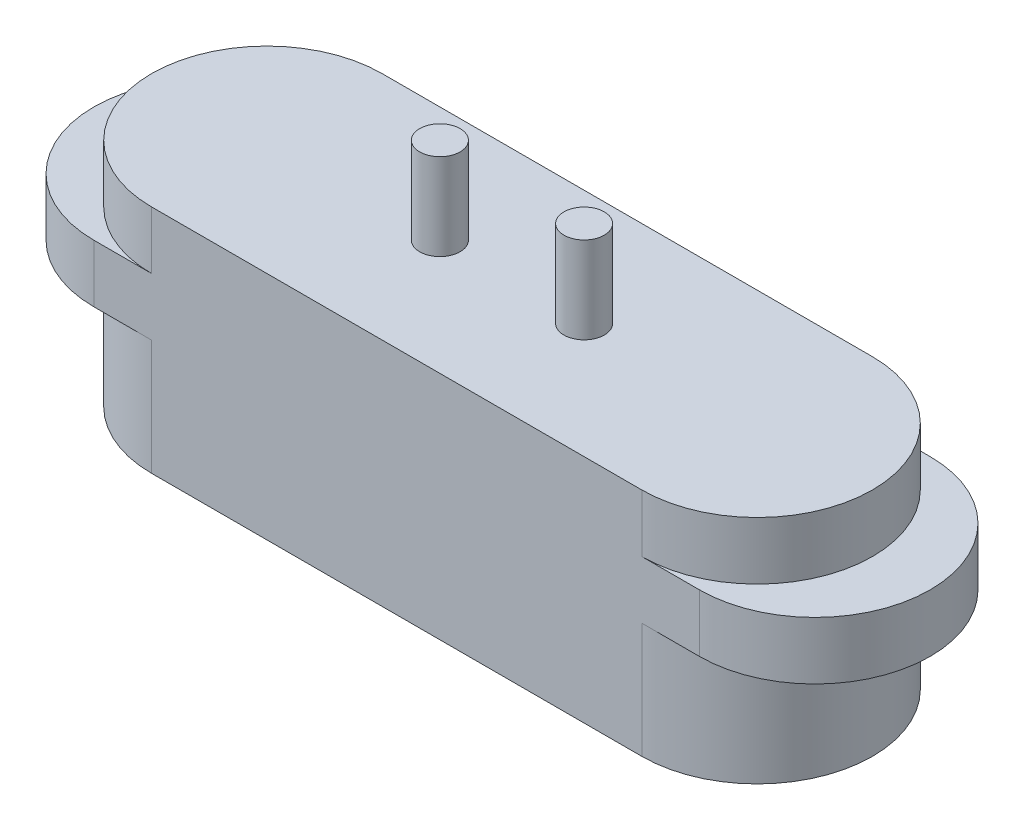
from build123d import *

# Parameters (mm, degrees)
BOSS_EXTRUDE1_DEPTH = 4
BOSS_EXTRUDE2_START = 2
BOSS_EXTRUDE2_DEPTH = 1
SKETCH2_R           = 0.35
BOSS_EXTRUDE3_DEPTH = 1.5
SKETCH3_R           = 0.75
SKETCH3_R_2         = 1.25
CUT_EXTRUDE1_DEPTH  = 0.01


with BuildPart() as part:
    # Sketch1 → Boss-Extrude1 (new body)
    with BuildSketch(Plane(origin=(0, 0, 0), x_dir=(1, 0, 0), z_dir=(0, 1, 0))):
        with BuildLine():
            Line((4.25, 2), (-4.25, 2))
            ThreePointArc((-4.25, 2), (-6.25, 0), (-4.25, -2))
            Line((-4.25, -2), (4.25, -2))
            ThreePointArc((4.25, -2), (6.25, 0), (4.25, 2))
        make_face()
    extrude(amount=BOSS_EXTRUDE1_DEPTH)

    # Sketch1_3 → Boss-Extrude2 (add)
    with BuildSketch(Plane(origin=(0, 0, 0), x_dir=(1, 0, 0), z_dir=(0, 1, 0)).offset(BOSS_EXTRUDE2_START)):
        with BuildLine():
            Line((-4.25, 2), (-5.25, 2))
            ThreePointArc((-5.25, 2), (-7.25, 0), (-5.25, -2))
            Line((-5.25, -2), (-4.25, -2))
            ThreePointArc((-4.25, -2), (-6.25, 0), (-4.25, 2))
        make_face()
        with BuildLine():
            Line((5.25, 2), (4.25, 2))
            ThreePointArc((4.25, 2), (6.25, 0), (4.25, -2))
            Line((4.25, -2), (5.25, -2))
            ThreePointArc((5.25, -2), (7.25, 0), (5.25, 2))
        make_face()
    extrude(amount=BOSS_EXTRUDE2_DEPTH)

    # Sketch2 → Boss-Extrude3 (add)
    with BuildSketch(Plane(origin=(0, 4, 0), x_dir=(1, 0, 0), z_dir=(0, 1, 0))):
        with Locations((-1.25, 0)):
            Circle(SKETCH2_R)
        with Locations((1.25, 0)):
            Circle(SKETCH2_R)
    extrude(amount=BOSS_EXTRUDE3_DEPTH)

    # Sketch3 → Cut-Extrude1 (cut)
    with BuildSketch(Plane.XZ):
        with Locations((-1.25, 0)):
            Circle(SKETCH3_R)
        with Locations((1.25, 0)):
            Circle(SKETCH3_R)
        with Locations((-4.25, 0)):
            Circle(SKETCH3_R_2)
        with Locations((4.25, 0)):
            Circle(SKETCH3_R_2)
    extrude(amount=-CUT_EXTRUDE1_DEPTH, mode=Mode.SUBTRACT)


solid = part.part
